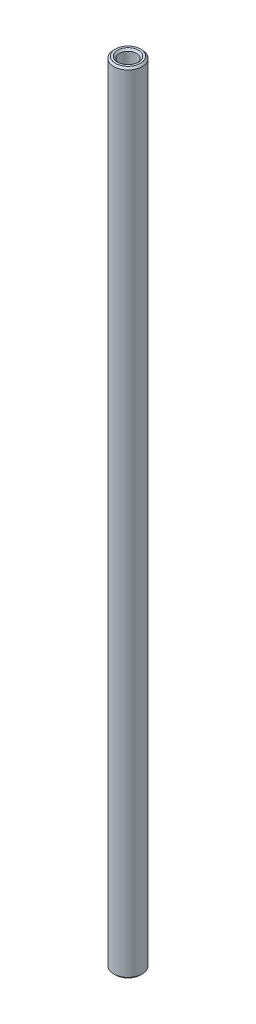
from build123d import *

# Parameters (mm, degrees)
SKETCH1_R           = 1.984375
SKETCH1_R_2         = 1.190625
BOSS_EXTRUDE1_DEPTH = 54.76875
CHAMFER1_SIZE       = 0.254


with BuildPart() as part:
    # Sketch1 → Boss-Extrude1 (new body, symmetric)
    with BuildSketch(Plane(origin=(0, 0, 0), x_dir=(1, 0, 0), z_dir=(0, 1, 0))):
        Circle(SKETCH1_R)
        Circle(SKETCH1_R_2, mode=Mode.SUBTRACT)
    extrude(amount=BOSS_EXTRUDE1_DEPTH, both=True)

    # Chamfer1
    chamfer1_edges = [part.edges().sort_by_distance(p)[0] for p in [
        (-1.984375, -54.76875, 0),
        (-1.984375, 54.76875, 0),
        (-1.190625, -54.76875, 0),
        (-1.190625, 54.76875, 0),
    ]]
    chamfer(chamfer1_edges, length=CHAMFER1_SIZE)


solid = part.part
